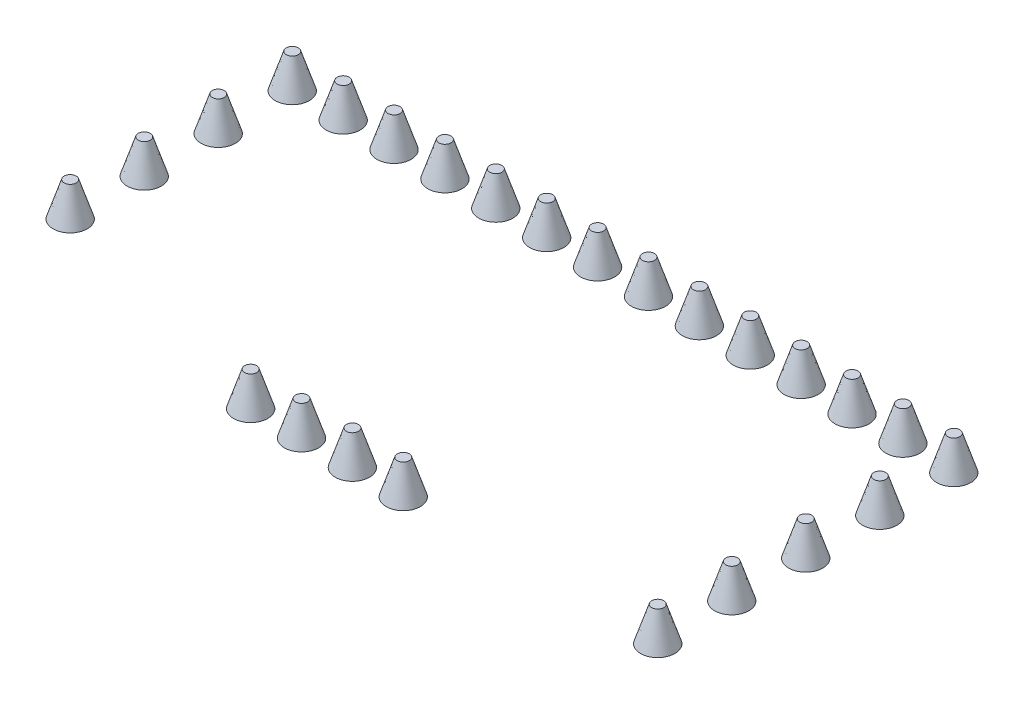
from build123d import *

# Parameters (mm, degrees)
PATTERN_LINEAR_3_COUNT = 4
PATTERN_LINEAR_3_PITCH = 160
PATTERN_LINEAR_4_COUNT = 14
PATTERN_LINEAR_4_PITCH = 110
PATTERN_LINEAR_5_COUNT = 5
PATTERN_LINEAR_5_PITCH = 160
PATTERN_LINEAR_6_COUNT = 2
PATTERN_LINEAR_6_PITCH = 550
PATTERN_LINEAR_7_COUNT = 4
PATTERN_LINEAR_7_PITCH = 110


with BuildPart() as part:
    # 草图2 → 旋转1 (revolve)
    with BuildSketch(Plane.XY):
        Polygon((0, -0.545321134), (0, 73.454678866), (13, 73.454678866), (37, -0.545321134), align=None)
    revolve(axis=Axis((0, -0.545321134, 0), (0, 1, 0)))


with BuildPart() as pattern_linear_3_1:
    # 阵列(线性)3: pattern copy
    add(part.part.moved(Location(Vector(0, 0, 1) * (1 * PATTERN_LINEAR_3_PITCH))))


with BuildPart() as pattern_linear_3_2:
    # 阵列(线性)3: pattern copy
    add(part.part.moved(Location(Vector(0, 0, 1) * (2 * PATTERN_LINEAR_3_PITCH))))


with BuildPart() as pattern_linear_3_3:
    # 阵列(线性)3: pattern copy
    add(part.part.moved(Location(Vector(0, 0, 1) * (3 * PATTERN_LINEAR_3_PITCH))))


with BuildPart() as pattern_linear_4_1:
    # 阵列(线性)4: pattern copy
    add(part.part.moved(Location(Vector(1, 0, 0) * (1 * PATTERN_LINEAR_4_PITCH))))


with BuildPart() as pattern_linear_4_2:
    # 阵列(线性)4: pattern copy
    add(part.part.moved(Location(Vector(1, 0, 0) * (2 * PATTERN_LINEAR_4_PITCH))))


with BuildPart() as pattern_linear_4_3:
    # 阵列(线性)4: pattern copy
    add(part.part.moved(Location(Vector(1, 0, 0) * (3 * PATTERN_LINEAR_4_PITCH))))


with BuildPart() as pattern_linear_4_4:
    # 阵列(线性)4: pattern copy
    add(part.part.moved(Location(Vector(1, 0, 0) * (4 * PATTERN_LINEAR_4_PITCH))))


with BuildPart() as pattern_linear_4_5:
    # 阵列(线性)4: pattern copy
    add(part.part.moved(Location(Vector(1, 0, 0) * (5 * PATTERN_LINEAR_4_PITCH))))


with BuildPart() as pattern_linear_4_6:
    # 阵列(线性)4: pattern copy
    add(part.part.moved(Location(Vector(1, 0, 0) * (6 * PATTERN_LINEAR_4_PITCH))))


with BuildPart() as pattern_linear_4_7:
    # 阵列(线性)4: pattern copy
    add(part.part.moved(Location(Vector(1, 0, 0) * (7 * PATTERN_LINEAR_4_PITCH))))


with BuildPart() as pattern_linear_4_8:
    # 阵列(线性)4: pattern copy
    add(part.part.moved(Location(Vector(1, 0, 0) * (8 * PATTERN_LINEAR_4_PITCH))))


with BuildPart() as pattern_linear_4_9:
    # 阵列(线性)4: pattern copy
    add(part.part.moved(Location(Vector(1, 0, 0) * (9 * PATTERN_LINEAR_4_PITCH))))


with BuildPart() as pattern_linear_4_10:
    # 阵列(线性)4: pattern copy
    add(part.part.moved(Location(Vector(1, 0, 0) * (10 * PATTERN_LINEAR_4_PITCH))))


with BuildPart() as pattern_linear_4_11:
    # 阵列(线性)4: pattern copy
    add(part.part.moved(Location(Vector(1, 0, 0) * (11 * PATTERN_LINEAR_4_PITCH))))


with BuildPart() as pattern_linear_4_12:
    # 阵列(线性)4: pattern copy
    add(part.part.moved(Location(Vector(1, 0, 0) * (12 * PATTERN_LINEAR_4_PITCH))))


with BuildPart() as pattern_linear_4_13:
    # 阵列(线性)4: pattern copy
    add(part.part.moved(Location(Vector(1, 0, 0) * (13 * PATTERN_LINEAR_4_PITCH))))


with BuildPart() as pattern_linear_5_1:
    # 阵列(线性)5: pattern copy
    add(pattern_linear_4_13.part.moved(Location(Vector(0, 0, 1) * (1 * PATTERN_LINEAR_5_PITCH))))


with BuildPart() as pattern_linear_5_2:
    # 阵列(线性)5: pattern copy
    add(pattern_linear_4_13.part.moved(Location(Vector(0, 0, 1) * (2 * PATTERN_LINEAR_5_PITCH))))


with BuildPart() as pattern_linear_5_3:
    # 阵列(线性)5: pattern copy
    add(pattern_linear_4_13.part.moved(Location(Vector(0, 0, 1) * (3 * PATTERN_LINEAR_5_PITCH))))


with BuildPart() as pattern_linear_5_4:
    # 阵列(线性)5: pattern copy
    add(pattern_linear_4_13.part.moved(Location(Vector(0, 0, 1) * (4 * PATTERN_LINEAR_5_PITCH))))


with BuildPart() as pattern_linear_6_1:
    # 阵列(线性)6: pattern copy
    add(pattern_linear_5_4.part.moved(Location(Vector(-1, 0, 0) * (1 * PATTERN_LINEAR_6_PITCH))))


with BuildPart() as pattern_linear_7_1:
    # 阵列(线性)7: pattern copy
    add(pattern_linear_6_1.part.moved(Location(Vector(-1, 0, 0) * (1 * PATTERN_LINEAR_7_PITCH))))


with BuildPart() as pattern_linear_7_2:
    # 阵列(线性)7: pattern copy
    add(pattern_linear_6_1.part.moved(Location(Vector(-1, 0, 0) * (2 * PATTERN_LINEAR_7_PITCH))))


with BuildPart() as pattern_linear_7_3:
    # 阵列(线性)7: pattern copy
    add(pattern_linear_6_1.part.moved(Location(Vector(-1, 0, 0) * (3 * PATTERN_LINEAR_7_PITCH))))


solid = Compound([part.part, pattern_linear_3_1.part, pattern_linear_3_2.part, pattern_linear_3_3.part, pattern_linear_4_1.part, pattern_linear_4_2.part, pattern_linear_4_3.part, pattern_linear_4_4.part, pattern_linear_4_5.part, pattern_linear_4_6.part, pattern_linear_4_7.part, pattern_linear_4_8.part, pattern_linear_4_9.part, pattern_linear_4_10.part, pattern_linear_4_11.part, pattern_linear_4_12.part, pattern_linear_4_13.part, pattern_linear_5_1.part, pattern_linear_5_2.part, pattern_linear_5_3.part, pattern_linear_5_4.part, pattern_linear_6_1.part, pattern_linear_7_1.part, pattern_linear_7_2.part, pattern_linear_7_3.part])
